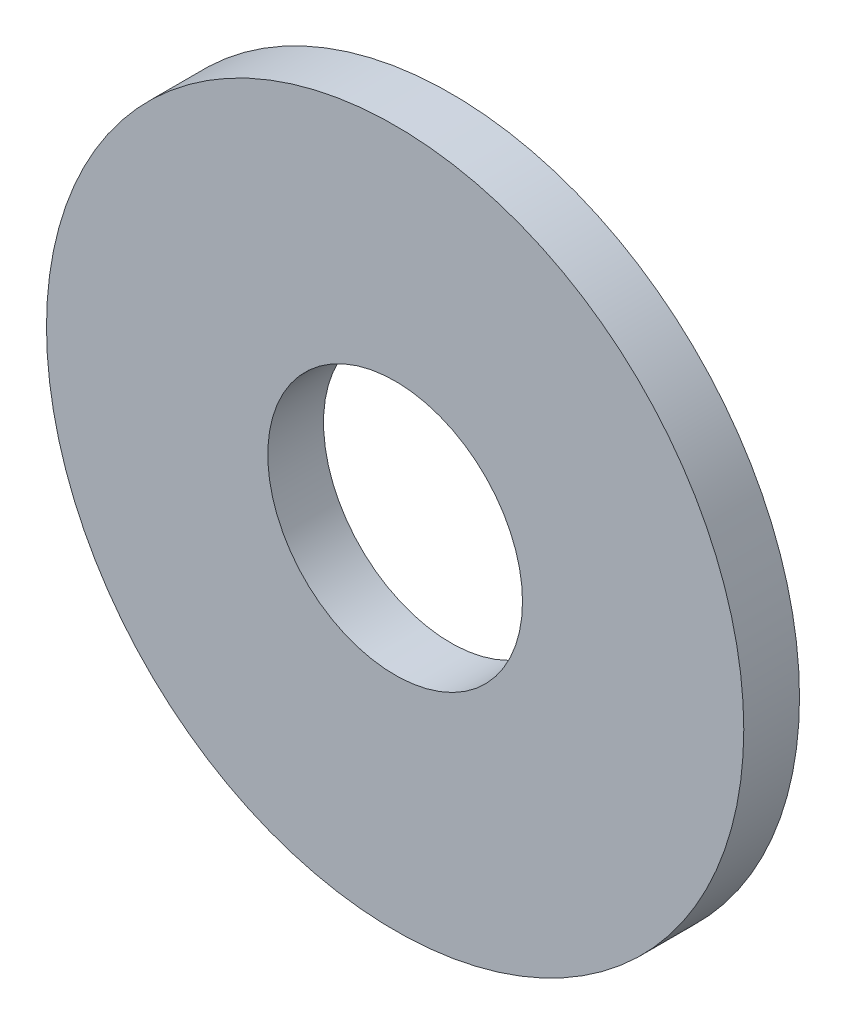
from build123d import *

# Parameters (mm, degrees)
BODY_SKETCH_R   = 4.38
BODY_SKETCH_R_2 = 1.6
BODY_DEPTH      = 0.7


with BuildPart() as part:
    # body_sketch → body (new body)
    with BuildSketch(Plane.XY):
        Circle(BODY_SKETCH_R)
        Circle(BODY_SKETCH_R_2, mode=Mode.SUBTRACT)
    extrude(amount=BODY_DEPTH)


solid = part.part
